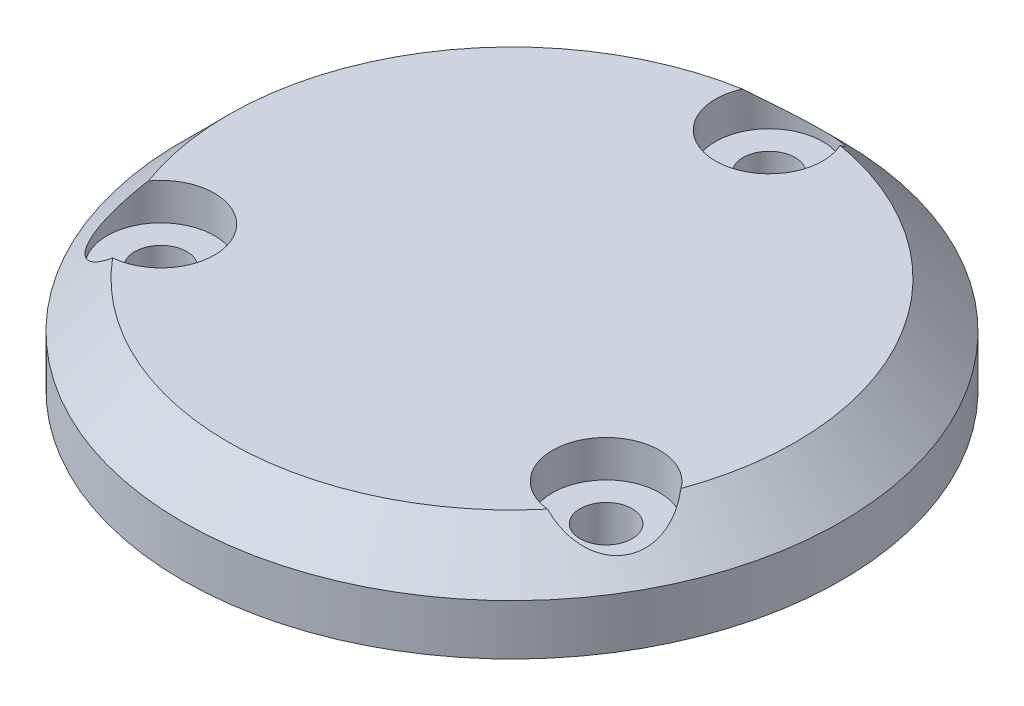
from build123d import *

# Parameters (mm, degrees)
SZKIC2_R                                             = 21.5
DODANIE_WYCI_GNI_CIE1_DEPTH                          = 3.3
DODANIE_WYCI_GNI_CIE1_OTHER_WAY_DEPTH                = 3
DODANIE_WYCI_GNI_CIE1_OTHER_WAY_TAPER                = 45
POG_BIENIE_WALCOWE_POD_M3_WKR_T_DO_CZ_CI_D           = 3.4
POG_BIENIE_WALCOWE_POD_M3_WKR_T_DO_CZ_CI_CBORE_D     = 7
POG_BIENIE_WALCOWE_POD_M3_WKR_T_DO_CZ_CI_CBORE_DEPTH = 2.4
SZYK_KO_OWY1_COUNT                                   = 3


with BuildPart() as part:
    # Szkic2 → Dodanie-wyciągnięcie1 (new body)
    with BuildSketch(Plane(origin=(0, 0, 0), x_dir=(1, 0, 0), z_dir=(0, 1, 0))):
        Circle(SZKIC2_R)
    extrude(amount=-DODANIE_WYCI_GNI_CIE1_DEPTH)

    # Szkic2 → Dodanie-wyciągnięcie1 other way (add)
    with BuildSketch(Plane(origin=(0, 0, 0), x_dir=(1, 0, 0), z_dir=(0, 1, 0))):
        Circle(SZKIC2_R)
    extrude(amount=DODANIE_WYCI_GNI_CIE1_OTHER_WAY_DEPTH, taper=DODANIE_WYCI_GNI_CIE1_OTHER_WAY_TAPER)

    # Pogłębienie walcowe pod M3 wkręt do części metalowych z łbem stożkowym ściętym2 (through all)
    with Locations(Plane(origin=(0, 3, 0), x_dir=(1, 0, 0), z_dir=(0, 1, 0))):
        with Locations((0, 16.772140565)):
            pog_bienie_walcowe_pod_m3_wkr_t_do_cz_ci = CounterBoreHole(POG_BIENIE_WALCOWE_POD_M3_WKR_T_DO_CZ_CI_D / 2, POG_BIENIE_WALCOWE_POD_M3_WKR_T_DO_CZ_CI_CBORE_D / 2, POG_BIENIE_WALCOWE_POD_M3_WKR_T_DO_CZ_CI_CBORE_DEPTH)

    # Szyk kołowy1: Pogłębienie walcowe pod M3 wkręt do części metalowych z łbem stożkowym ściętym2 ×3 about axis
    szyk_ko_owy1_axis = Axis((0, 0, 0), (0, 1, 0))
    for i in range(1, SZYK_KO_OWY1_COUNT):
        add(pog_bienie_walcowe_pod_m3_wkr_t_do_cz_ci.rotate(szyk_ko_owy1_axis, i * 360 / SZYK_KO_OWY1_COUNT), mode=Mode.SUBTRACT)


solid = part.part
